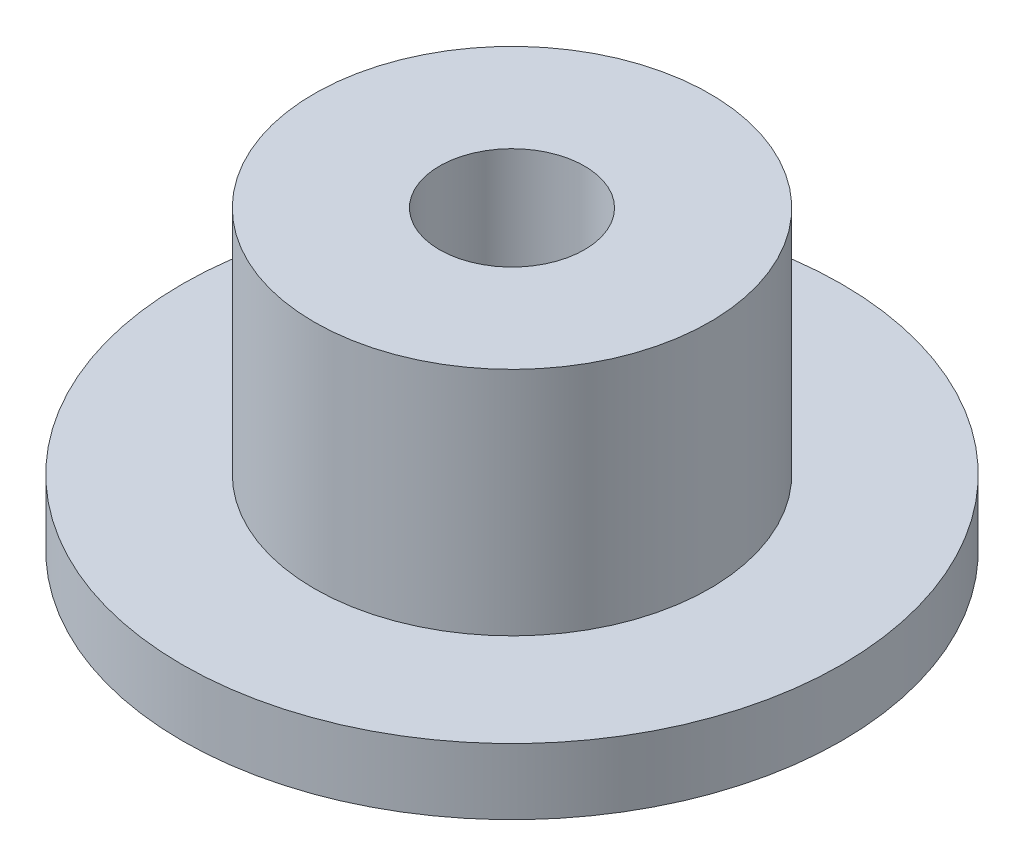
from build123d import *


with BuildPart() as part:
    # Croquis1 → Revolución1 (revolve)
    with BuildSketch(Plane.XY):
        Polygon((2.2, 9), (2.2, 3), (4.1, 3), (4.1, 0.6), (4.65, 0.6), (4.65, 0), (10, 0), (10, 2), (6, 2), (6, 9), align=None)
    revolve(axis=Axis((0, 11.719090396, 0), (0, -1, 0)))


solid = part.part
